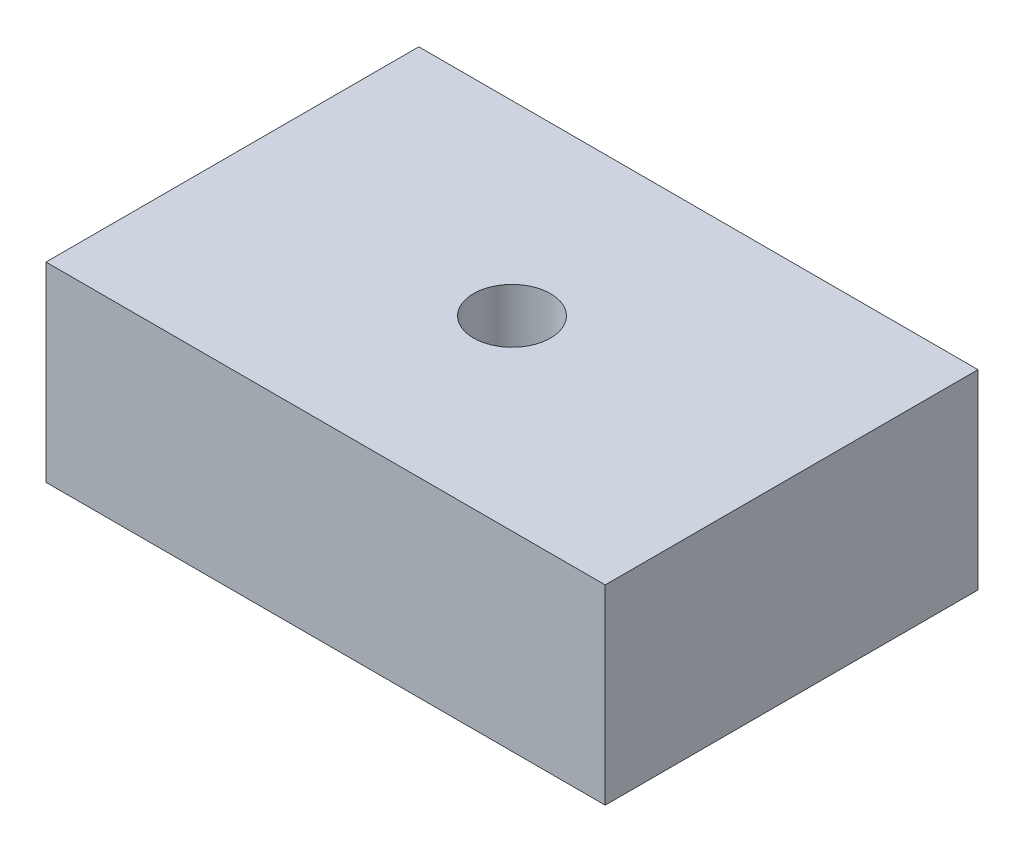
from build123d import *

# Parameters (mm, degrees)
SKETCH1_W           = 76.2
SKETCH1_H           = 50.8
SKETCH1_R           = 5.25
BOSS_EXTRUDE1_DEPTH = 26


with BuildPart() as part:
    # Sketch1 → Boss-Extrude1 (new body)
    with BuildSketch(Plane(origin=(0, 0, 0), x_dir=(1, 0, 0), z_dir=(0, 1, 0))):
        Rectangle(SKETCH1_W, SKETCH1_H)
        Circle(SKETCH1_R, mode=Mode.SUBTRACT)
    extrude(amount=BOSS_EXTRUDE1_DEPTH)


solid = part.part
